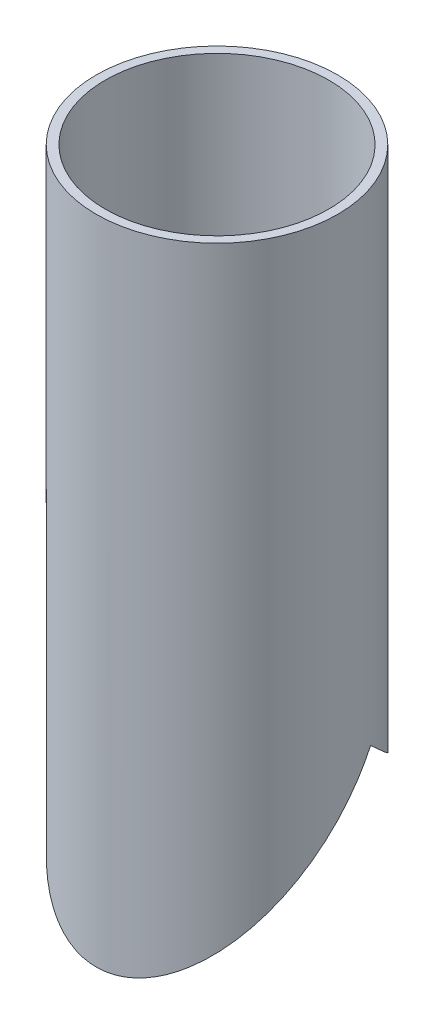
from build123d import *

# Parameters (mm, degrees)
SKETCH1_W               = 1.651
SKETCH1_H               = 120.65
CUT_EXTRUDE1_DEPTH      = 20.685
CUT_EXTRUDE1_DEPTH_BACK = 25.765


with BuildPart() as part:
    # Sketch1 → Revolve1 (revolve)
    with BuildSketch(Plane(origin=(0, 0, 0), x_dir=(0, 0, -1), z_dir=(1, 0, 0))):
        with Locations((21.3995, 60.325)):
            Rectangle(SKETCH1_W, SKETCH1_H)
    revolve(axis=Axis((0, 0, 0), (0, 1, 0)))

    # Sketch3 → Cut-Extrude1 (cut, two sides)
    with BuildSketch(Plane(origin=(2.54, 0, 0), x_dir=(0, 0, -1), z_dir=(1, 0, 0))) as cut_extrude1_sk:
        Polygon((22.225, 17.557770233), (22.225, 0), (-22.225, 0), (-22.225, 0.673713291), (7.273845181, 31.75), align=None)
    extrude(amount=CUT_EXTRUDE1_DEPTH, mode=Mode.SUBTRACT)
    extrude(cut_extrude1_sk.sketch, amount=-CUT_EXTRUDE1_DEPTH_BACK, mode=Mode.SUBTRACT)


solid = part.part
